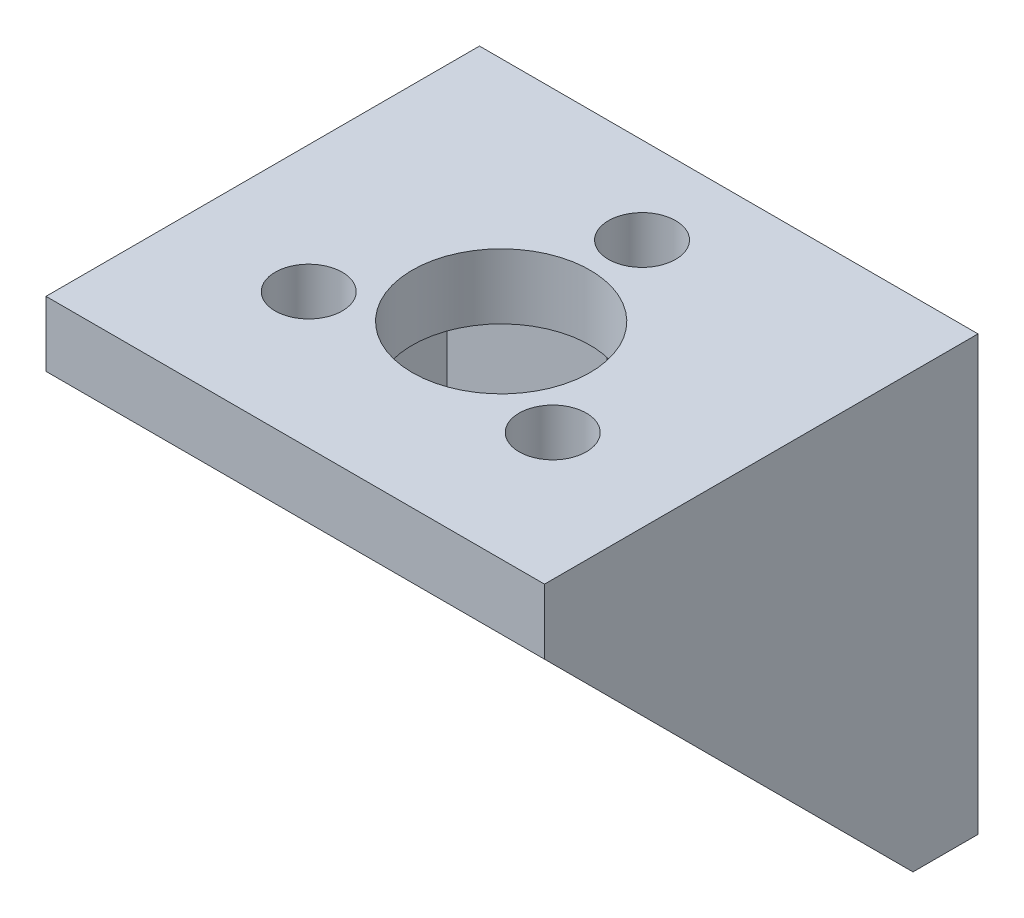
from build123d import *

# Parameters (mm, degrees)
BOSS_EXTRUDE1_DEPTH   = 11.5
SKETCH2_W             = 17
SKETCH2_H             = 17
CUT_EXTRUDE1_DEPTH    = 10
CUT_EXTRUDE2_REACH    = 5
CORTE_EXTRUS_O1_REACH = 22
ESBO_O1_R             = 4.1
ESBO_O6_R             = 1.55
CORTE_EXTRUS_O5_DEPTH = 21
PADR_OCIRCULAR2_COUNT = 3
ESBO_O11_R            = 2.8
CORTE_EXTRUS_O8_DEPTH = 18.0000001


with BuildPart() as part:
    # Sketch1 → Boss-Extrude1 (new body, symmetric)
    with BuildSketch(Plane(origin=(0, 0, 0), x_dir=(0, 0, -1), z_dir=(1, 0, 0))):
        Polygon((0, 0), (-20, 0), (-20, -3), (-11.5, -11.5), (-3, -20), (0, -20), align=None)
    extrude(amount=BOSS_EXTRUDE1_DEPTH, both=True)

    # Sketch2 → Cut-Extrude1 (cut, symmetric)
    with BuildSketch(Plane(origin=(0, 0, 0), x_dir=(0, 0, -1), z_dir=(1, 0, 0))):
        with Locations((-11.5, -11.5)):
            Rectangle(SKETCH2_W, SKETCH2_H)
    extrude(amount=CUT_EXTRUDE1_DEPTH, both=True, mode=Mode.SUBTRACT)

    # Sketch3 → Cut-Extrude2 (cut, up to next)
    with BuildSketch(Plane.XY.offset(3), mode=Mode.PRIVATE) as cut_extrude2_sk1:
        with BuildLine():
            Line((-3, -9), (-3, -12))
            ThreePointArc((-3, -12), (0, -15), (3, -12))
            Line((3, -12), (3, -9))
            ThreePointArc((3, -9), (0, -6), (-3, -9))
        make_face()
    cut_extrude2_tool1 = extrude(cut_extrude2_sk1.sketch, amount=-CUT_EXTRUDE2_REACH, mode=Mode.PRIVATE) & part.part
    add(cut_extrude2_tool1.solids().sort_by_distance((0, -10.5, 3))[0], mode=Mode.SUBTRACT)

    # Esboço1 → Corte-extrusão1 (cut, up to next)
    with BuildSketch(Plane(origin=(0, 0, 0), x_dir=(1, 0, 0), z_dir=(0, 1, 0)), mode=Mode.PRIVATE) as corte_extrus_o1_sk1:
        with Locations((0, -10.5)):
            Circle(ESBO_O1_R)
    corte_extrus_o1_tool1 = extrude(corte_extrus_o1_sk1.sketch, amount=-CORTE_EXTRUS_O1_REACH, mode=Mode.PRIVATE) & part.part
    add(corte_extrus_o1_tool1.solids().sort_by_distance((0, 0, 10.5))[0], mode=Mode.SUBTRACT)

    # Esboço6 → Corte-extrusão5 (cut, through all)
    with BuildSketch(Plane(origin=(0, 0, 0), x_dir=(1, 0, 0), z_dir=(0, 1, 0))):
        with Locations((0, -4)):
            Circle(ESBO_O6_R)
    corte_extrus_o5 = extrude(amount=-CORTE_EXTRUS_O5_DEPTH, mode=Mode.SUBTRACT)

    # PadrãoCircular2: Corte-extrusão5 ×3 about axis
    padr_ocircular2_axis = Axis((0, 0, 10.5), (0, 1, 0))
    for i in range(1, PADR_OCIRCULAR2_COUNT):
        add(corte_extrus_o5.rotate(padr_ocircular2_axis, i * 360 / PADR_OCIRCULAR2_COUNT), mode=Mode.SUBTRACT)

    # Esboço11 → Corte-extrusão8 (cut, through all)
    with BuildSketch(Plane.XZ.offset(3)):
        with Locations((0, 4)):
            Circle(ESBO_O11_R)
    extrude(amount=CORTE_EXTRUS_O8_DEPTH, mode=Mode.SUBTRACT)


solid = part.part
